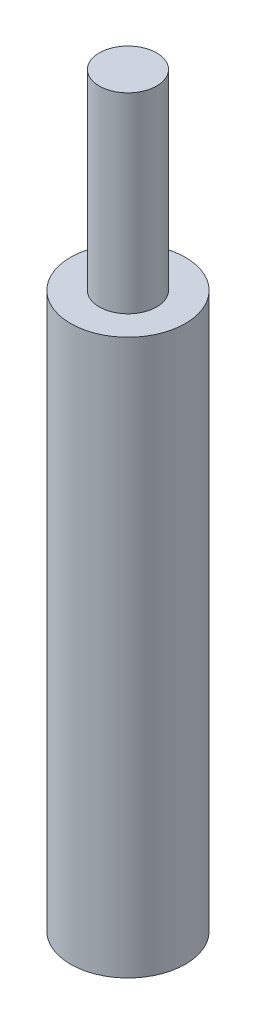
from build123d import *

# Parameters (mm, degrees)
SKETCH1_R                       = 3
BOSS_EXTRUDE1_DEPTH             = 29
SKETCH2_R                       = 1.5
BOSS_EXTRUDE2_DEPTH             = 10
M3X0_5_TAPPED_HOLE1_D           = 2.5
M3X0_5_TAPPED_HOLE1_DEPTH       = 5
M3X0_5_TAPPED_HOLE1_CSINK_D     = 3.05
M3X0_5_TAPPED_HOLE1_CSINK_ANGLE = 90
M3X0_5_TAPPED_HOLE1_TIP         = 0.751075774


with BuildPart() as part:
    # Sketch1 → Boss-Extrude1 (new body)
    with BuildSketch(Plane(origin=(0, 0, 0), x_dir=(1, 0, 0), z_dir=(0, 1, 0))):
        Circle(SKETCH1_R)
    extrude(amount=BOSS_EXTRUDE1_DEPTH)

    # Sketch2 → Boss-Extrude2 (add)
    with BuildSketch(Plane(origin=(0, 29, 0), x_dir=(1, 0, 0), z_dir=(0, 1, 0))):
        Circle(SKETCH2_R)
    extrude(amount=BOSS_EXTRUDE2_DEPTH)

    # M3x0.5 Tapped Hole1
    with Locations(Plane(origin=(0, 0, 0), x_dir=(-1, 0, 0), z_dir=(0, -1, 0))):
        with Locations((0, 0)):
            CounterSinkHole(M3X0_5_TAPPED_HOLE1_D / 2, M3X0_5_TAPPED_HOLE1_CSINK_D / 2, depth=M3X0_5_TAPPED_HOLE1_DEPTH, counter_sink_angle=M3X0_5_TAPPED_HOLE1_CSINK_ANGLE)
            with Locations((0, 0, -(M3X0_5_TAPPED_HOLE1_DEPTH + M3X0_5_TAPPED_HOLE1_TIP / 2))):  # 118° drill point
                Cone(0, M3X0_5_TAPPED_HOLE1_D / 2, M3X0_5_TAPPED_HOLE1_TIP, mode=Mode.SUBTRACT)


solid = part.part
